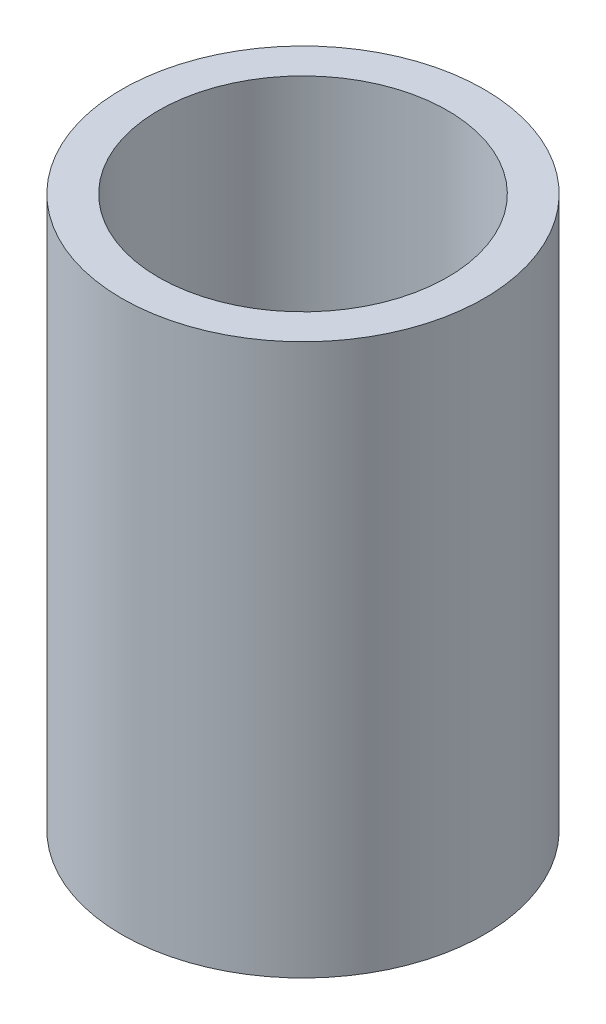
from build123d import *

# Parameters (mm, degrees)
SKETCH1_R           = 16.7005
SKETCH1_R_2         = 13.3223
BOSS_EXTRUDE1_DEPTH = 50.8


with BuildPart() as part:
    # Sketch1 → Boss-Extrude1 (new body)
    with BuildSketch(Plane(origin=(0, 0, 0), x_dir=(1, 0, 0), z_dir=(0, 1, 0))):
        Circle(SKETCH1_R)
        Circle(SKETCH1_R_2, mode=Mode.SUBTRACT)
    extrude(amount=BOSS_EXTRUDE1_DEPTH)


solid = part.part
